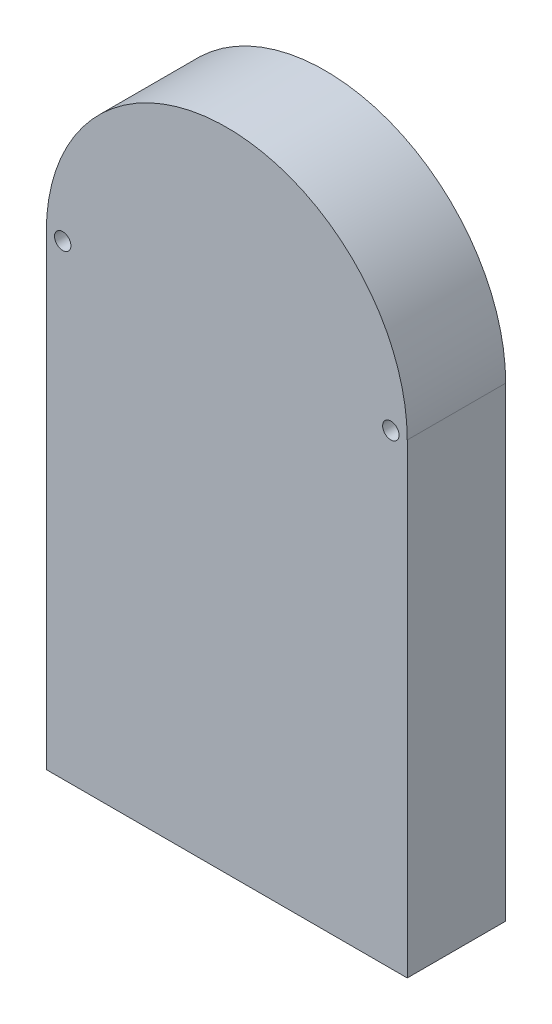
from build123d import *

# Parameters (mm, degrees)
BOSS_EXTRUDE1_DEPTH        = 30
CUT_EXTRUDE1_DEPTH         = 25
F_5_0MM_DOWEL_HOLE2_REACH  = 221.224
F_5_0MM_DOWEL_HOLE2_BORE_R = 2.5
F_5_0MM_DOWEL_HOLE4_D      = 5


with BuildPart() as part:
    # Sketch1 → Boss-Extrude1 (new body)
    with BuildSketch(Plane.XY):
        with BuildLine():
            Line((-57.251461988, 0), (52.748538012, 0))
            Line((52.748538012, 0), (52.748538012, 142))
            ThreePointArc((52.748538012, 142), (-2.251461988, 197), (-57.251461988, 142))
            Line((-57.251461988, 142), (-57.251461988, 0))
        make_face()
    extrude(amount=BOSS_EXTRUDE1_DEPTH)

    # Sketch8 → Cut-Extrude1 (cut)
    with BuildSketch(Plane(origin=(0, 0, 0), x_dir=(-1, 0, 0), z_dir=(0, 0, -1))):
        with BuildLine():
            Line((-42.748538012, 10), (47.251461988, 10))
            Line((47.251461988, 10), (47.251461988, 142))
            ThreePointArc((47.251461988, 142), (2.251461988, 187), (-42.748538012, 142))
            Line((-42.748538012, 142), (-42.748538012, 10))
        make_face()
    extrude(amount=-CUT_EXTRUDE1_DEPTH, mode=Mode.SUBTRACT)

    # Ø5.0mm Dowel Hole2 bore (on position points) → Ø5.0mm Dowel Hole2 (cut, up to next)
    with BuildSketch(Plane(origin=(-42.251461988, 0, 15), x_dir=(0, 0, -1), z_dir=(0, -1, 0)), mode=Mode.PRIVATE) as f_5_0mm_dowel_hole2_sk1:
        Circle(F_5_0MM_DOWEL_HOLE2_BORE_R)
    f_5_0mm_dowel_hole2_tool1 = extrude(f_5_0mm_dowel_hole2_sk1.sketch, amount=-F_5_0MM_DOWEL_HOLE2_REACH, mode=Mode.PRIVATE) & part.part
    # Ø5.0mm Dowel Hole2 bore (on position points) → Ø5.0mm Dowel Hole2 (cut, up to next)
    with BuildSketch(Plane(origin=(-42.251461988, 0, 15), x_dir=(0, 0, -1), z_dir=(0, -1, 0)), mode=Mode.PRIVATE) as f_5_0mm_dowel_hole2_sk2:
        with Locations((0, 80)):
            Circle(F_5_0MM_DOWEL_HOLE2_BORE_R)
    f_5_0mm_dowel_hole2_tool2 = extrude(f_5_0mm_dowel_hole2_sk2.sketch, amount=-F_5_0MM_DOWEL_HOLE2_REACH, mode=Mode.PRIVATE) & part.part
    add(f_5_0mm_dowel_hole2_tool1.solids().sort_by_distance((-42.251462, 0, 15))[0], mode=Mode.SUBTRACT)
    add(f_5_0mm_dowel_hole2_tool2.solids().sort_by_distance((37.748538, 0, 15))[0], mode=Mode.SUBTRACT)

    # Ø5.0mm Dowel Hole4 (through all)
    with Locations(Plane(origin=(47.748538012, 142, 0), x_dir=(-1, 0, 0), z_dir=(0, 0, -1))):
        with Locations((0, 0), (100, 0)):
            Hole(F_5_0MM_DOWEL_HOLE4_D / 2)


solid = part.part
